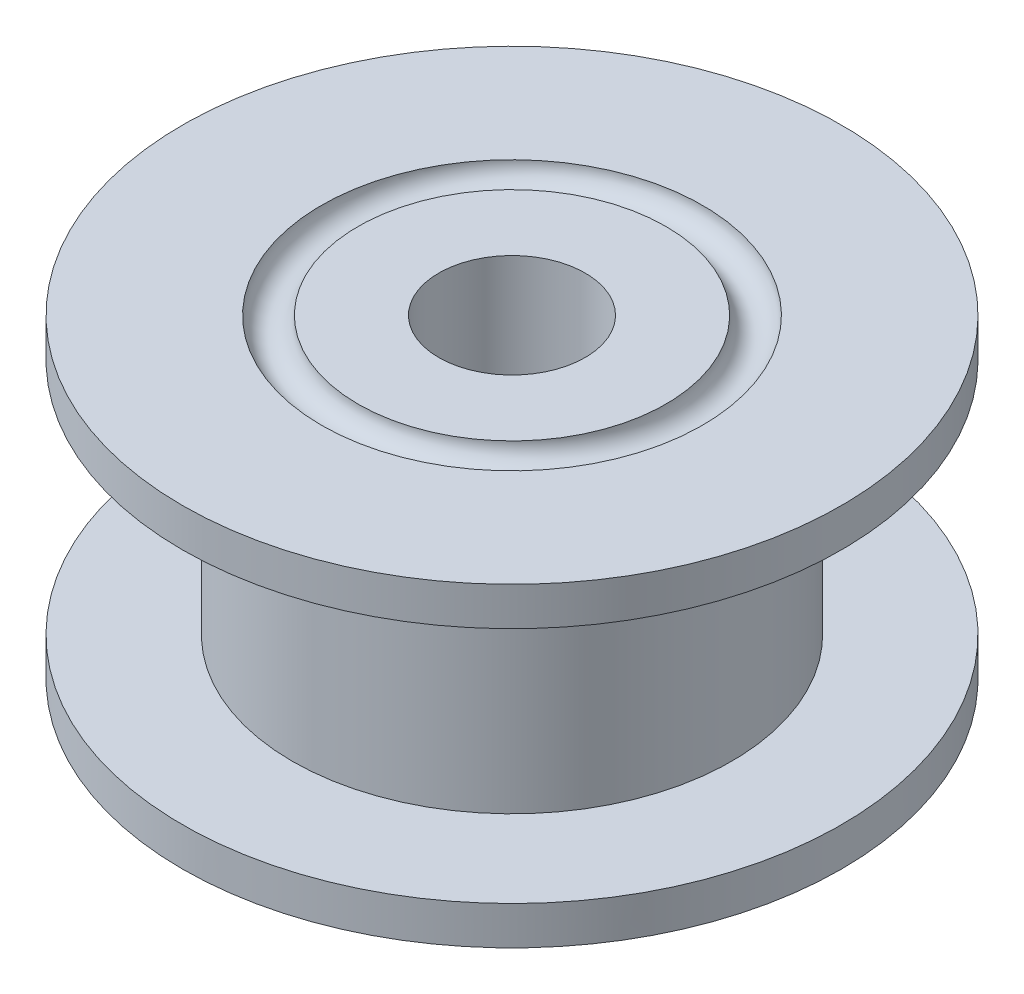
from build123d import *

# Parameters (mm, degrees)
SKETCH1_R            = 9
BOSS_EXTRUDE1_DEPTH  = 8.6
SKETCH2_W            = 9.699094827
SKETCH2_H            = 6.5
SKETCH3_R            = 2
CUT_EXTRUDE1_DEPTH   = 9.6
CUT_SWEEP2_PROFILE_R = 0.5
CUT_SWEEP3_PROFILE_R = 0.5


with BuildPart() as part:
    # Sketch1 → Boss-Extrude1 (new body)
    with BuildSketch(Plane(origin=(0, 0, 0), x_dir=(1, 0, 0), z_dir=(0, 1, 0))):
        Circle(SKETCH1_R)
    extrude(amount=BOSS_EXTRUDE1_DEPTH)

    # Sketch2 → Cut-Revolve1 (revolve, cut)
    with BuildSketch(Plane.XY):
        with Locations((-10.849547414, 4.3)):
            Rectangle(SKETCH2_W, SKETCH2_H)
    revolve(axis=Axis((0, 8.6, 0), (0, -1, 0)), mode=Mode.SUBTRACT)

    # Sketch3 → Cut-Extrude1 (cut, through all)
    with BuildSketch(Plane(origin=(0, 8.6, 0), x_dir=(1, 0, 0), z_dir=(0, 1, 0))):
        Circle(SKETCH3_R)
    extrude(amount=-CUT_EXTRUDE1_DEPTH, mode=Mode.SUBTRACT)

    # Cut-Sweep2: sweep along a path in Sketch4
    with BuildLine(Plane(origin=(0, 8.6, 0), x_dir=(1, 0, 0), z_dir=(0, 1, 0))) as cut_sweep2_path:
        CenterArc((0, 0), 4.703999497, 0, 360)
    # Cut-Sweep2 profile (on start of the path) → Cut-Sweep2 (sweep, cut)
    with BuildSketch(Plane(origin=(4.703999497, 8.6, 0), x_dir=(-1, 0, 0), z_dir=(0, 0, -1))):
        Circle(CUT_SWEEP2_PROFILE_R)
    sweep(path=cut_sweep2_path.line, mode=Mode.SUBTRACT)

    # Cut-Sweep3: sweep along a path in Sketch20
    with BuildLine(Plane.XZ) as cut_sweep3_path:
        CenterArc((0, 0), 4.7, 0, 360)
    # Cut-Sweep3 profile (on start of the path) → Cut-Sweep3 (sweep, cut)
    with BuildSketch(Plane(origin=(4.7, 0, 0), x_dir=(1, 0, 0), z_dir=(0, 0, 1))):
        Circle(CUT_SWEEP3_PROFILE_R)
    sweep(path=cut_sweep3_path.line, mode=Mode.SUBTRACT)


solid = part.part
